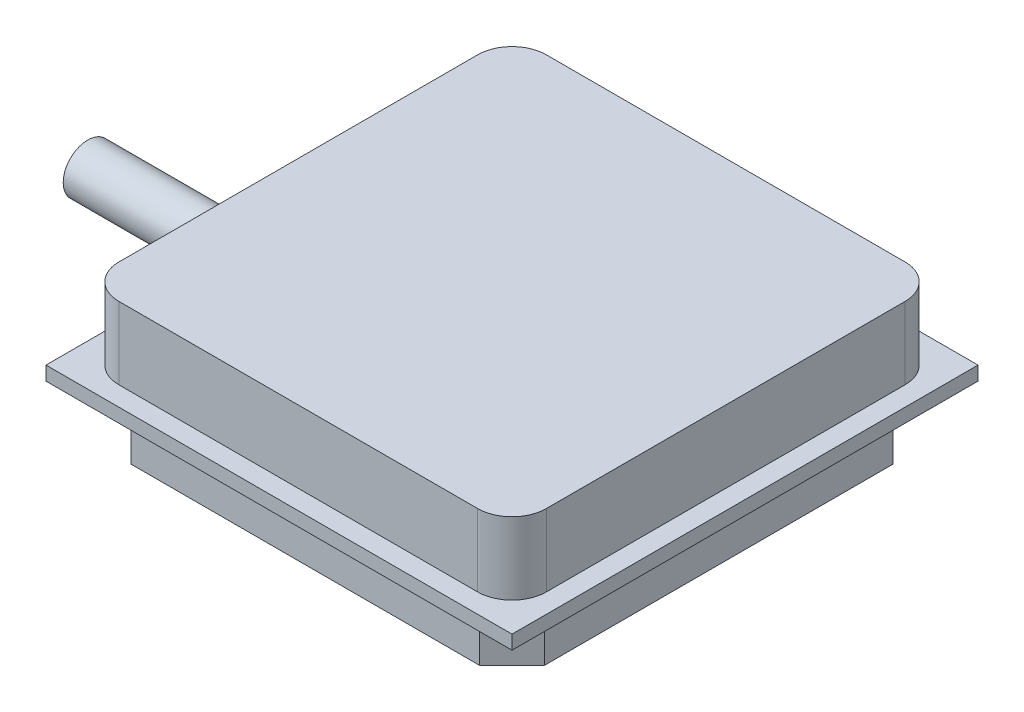
from build123d import *

# Parameters (mm, degrees)
SKETCH1_W           = 27.2034
SKETCH1_H           = 27.2034
BOSS_EXTRUDE1_DEPTH = 0.8128
BOSS_EXTRUDE2_DEPTH = 4.2164
BOSS_EXTRUDE3_DEPTH = 3.2512
SKETCH4_R           = 1.4351
BOSS_EXTRUDE4_DEPTH = 12.7


with BuildPart() as part:
    # Sketch1 → Boss-Extrude1 (new body)
    with BuildSketch(Plane(origin=(0, 0, 0), x_dir=(1, 0, 0), z_dir=(0, 1, 0))):
        with Locations((13.6017, 13.6017)):
            Rectangle(SKETCH1_W, SKETCH1_H)
    extrude(amount=BOSS_EXTRUDE1_DEPTH)

    # Sketch2 → Boss-Extrude2 (add)
    with BuildSketch(Plane(origin=(0, 0.8128, 0), x_dir=(1, 0, 0), z_dir=(0, 1, 0))):
        with BuildLine():
            Line((3.1303, 26.0731), (24.0731, 26.0731))
            ThreePointArc((24.0731, 26.0731), (25.487313562, 25.487313562), (26.0731, 24.0731))
            Line((26.0731, 24.0731), (26.0731, 3.1303))
            ThreePointArc((26.0731, 3.1303), (25.487313562, 1.716086438), (24.0731, 1.1303))
            Line((24.0731, 1.1303), (3.1303, 1.1303))
            ThreePointArc((3.1303, 1.1303), (1.716086438, 1.716086438), (1.1303, 3.1303))
            Line((1.1303, 3.1303), (1.1303, 24.0731))
            ThreePointArc((1.1303, 24.0731), (1.716086438, 25.487313562), (3.1303, 26.0731))
        make_face()
    extrude(amount=BOSS_EXTRUDE2_DEPTH)

    # Sketch3 → Boss-Extrude3 (add)
    with BuildSketch(Plane.XZ):
        Polygon((23.771814156, -1.5367), (3.431585844, -1.5367), (1.5367, -3.431585844), (1.5367, -23.771814156), (3.431585844, -25.6667), (23.771814156, -25.6667), (25.6667, -23.771814156), (25.6667, -3.431585844), align=None)
    extrude(amount=BOSS_EXTRUDE3_DEPTH)

    # Sketch4 → Boss-Extrude4 (add)
    with BuildSketch(Plane.ZY.offset(-1.5367)):
        with Locations((-13.6017, -1.6256)):
            Circle(SKETCH4_R)
    extrude(amount=BOSS_EXTRUDE4_DEPTH)


solid = part.part
